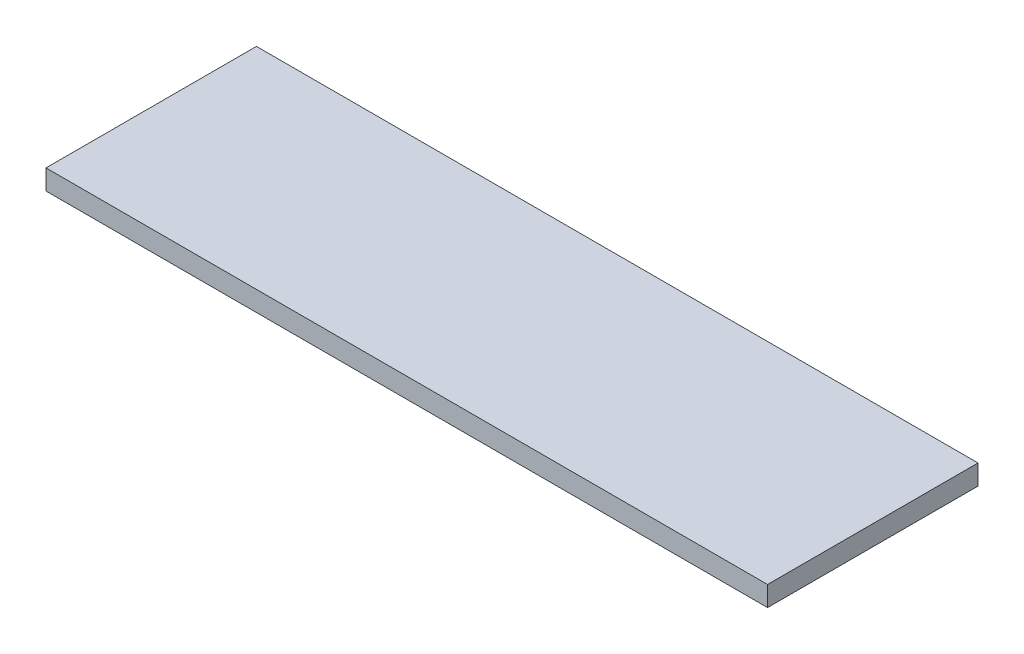
from build123d import *

# Parameters (mm, degrees)
SKETCH1_W           = 720
SKETCH1_H           = 210
BOSS_EXTRUDE1_DEPTH = 20


with BuildPart() as part:
    # Sketch1 → Boss-Extrude1 (new body)
    with BuildSketch(Plane(origin=(0, 0, 0), x_dir=(1, 0, 0), z_dir=(0, 1, 0))):
        Rectangle(SKETCH1_W, SKETCH1_H)
    extrude(amount=BOSS_EXTRUDE1_DEPTH)


solid = part.part
